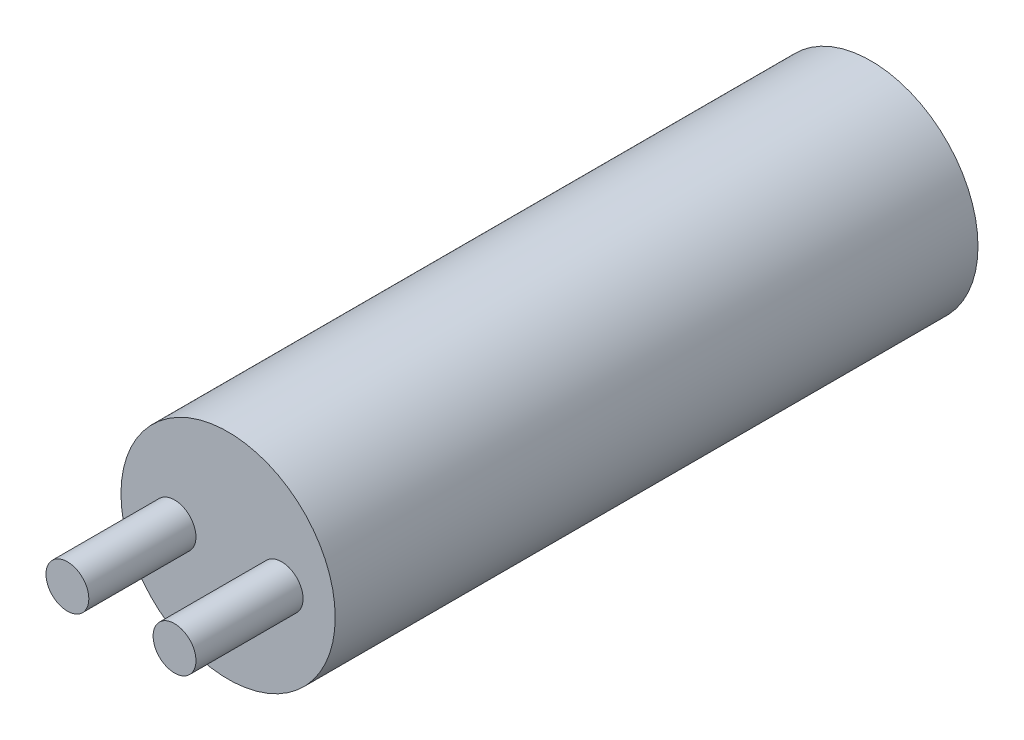
from build123d import *

# Parameters (mm, degrees)
SKETCH2_R           = 12.7
BOSS_EXTRUDE1_DEPTH = 101.6
BOSS_EXTRUDE2_DEPTH = 12.7
SKETCH4_R           = 14.196290171
CUT_EXTRUDE1_DEPTH  = 25.4


with BuildPart() as part:
    # Sketch2 → Boss-Extrude1 (new body)
    with BuildSketch(Plane.XY):
        Circle(SKETCH2_R)
    extrude(amount=BOSS_EXTRUDE1_DEPTH)

    # Sketch3 → Boss-Extrude2 (add)
    with BuildSketch(Plane.XY.offset(101.6)):
        with BuildLine():
            ThreePointArc((-8.89, 0), (-6.35, -2.54), (-3.81, 0))
            Line((-3.81, 0), (-8.89, 0))
        make_face()
        with BuildLine():
            Line((-8.89, 0), (-3.81, 0))
            ThreePointArc((-3.81, 0), (-6.35, 2.54), (-8.89, 0))
        make_face()
        with BuildLine():
            ThreePointArc((8.89, 0), (6.35, 2.54), (3.81, 0))
            Line((3.81, 0), (8.89, 0))
        make_face()
        with BuildLine():
            Line((8.89, 0), (3.81, 0))
            ThreePointArc((3.81, 0), (6.35, -2.54), (8.89, 0))
        make_face()
    extrude(amount=BOSS_EXTRUDE2_DEPTH)

    # Sketch4 → Cut-Extrude1 (cut)
    with BuildSketch(Plane(origin=(0, 0, 0), x_dir=(-1, 0, 0), z_dir=(0, 0, -1))):
        Circle(SKETCH4_R)
    extrude(amount=-CUT_EXTRUDE1_DEPTH, mode=Mode.SUBTRACT)


solid = part.part
